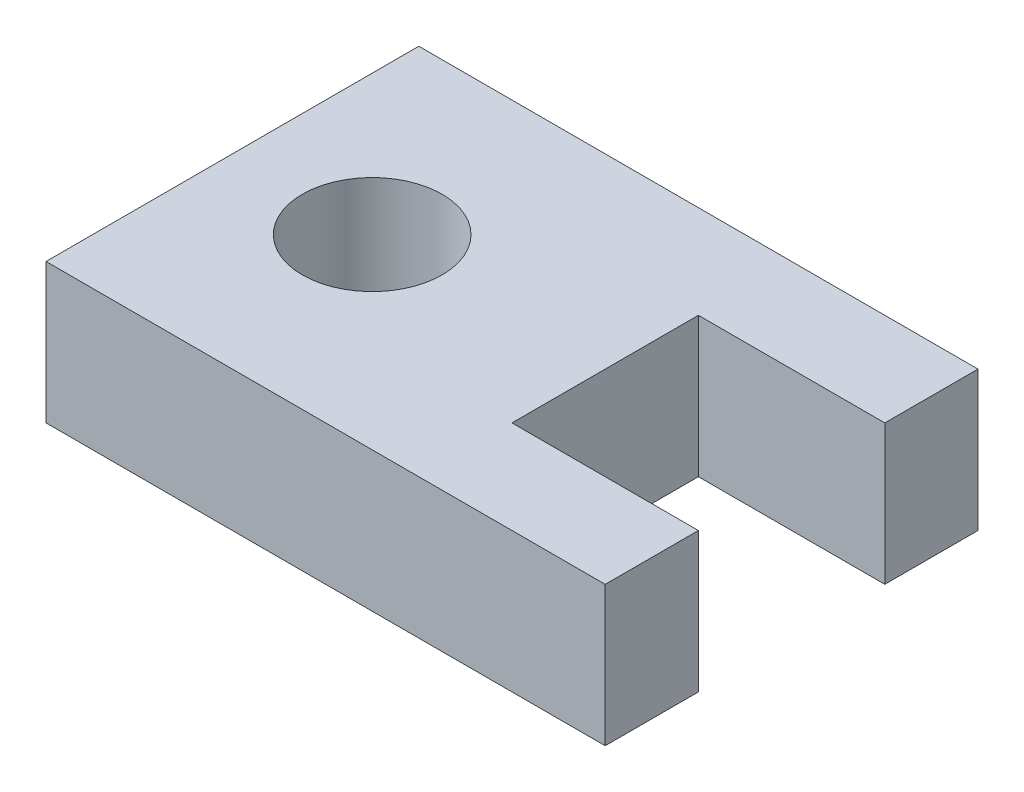
from build123d import *

# Parameters (mm, degrees)
SKETCH1_W           = 60
SKETCH1_H           = 40
BOSS_EXTRUDE1_DEPTH = 15
CUT_EXTRUDE1_REACH  = 17
SKETCH2_R           = 7.5
CUT_EXTRUDE2_REACH  = 17
SKETCH3_W           = 20
SKETCH3_H           = 20


with BuildPart() as part:
    # Sketch1 → Boss-Extrude1 (new body)
    with BuildSketch(Plane(origin=(0, 0, 0), x_dir=(1, 0, 0), z_dir=(0, 1, 0))):
        Rectangle(SKETCH1_W, SKETCH1_H)
    extrude(amount=BOSS_EXTRUDE1_DEPTH)

    # Sketch2 → Cut-Extrude1 (cut, up to next)
    with BuildSketch(Plane(origin=(0, 15, 0), x_dir=(1, 0, 0), z_dir=(0, 1, 0)), mode=Mode.PRIVATE) as cut_extrude1_sk1:
        with Locations((-15, 0)):
            Circle(SKETCH2_R)
    cut_extrude1_tool1 = extrude(cut_extrude1_sk1.sketch, amount=-CUT_EXTRUDE1_REACH, mode=Mode.PRIVATE) & part.part
    add(cut_extrude1_tool1.solids().sort_by_distance((-15, 15, 0))[0], mode=Mode.SUBTRACT)

    # Sketch3 → Cut-Extrude2 (cut, up to next)
    with BuildSketch(Plane(origin=(0, 15, 0), x_dir=(1, 0, 0), z_dir=(0, 1, 0)), mode=Mode.PRIVATE) as cut_extrude2_sk1:
        with Locations((20, 0)):
            Rectangle(SKETCH3_W, SKETCH3_H)
    cut_extrude2_tool1 = extrude(cut_extrude2_sk1.sketch, amount=-CUT_EXTRUDE2_REACH, mode=Mode.PRIVATE) & part.part
    add(cut_extrude2_tool1.solids().sort_by_distance((20, 15, 0))[0], mode=Mode.SUBTRACT)


solid = part.part
